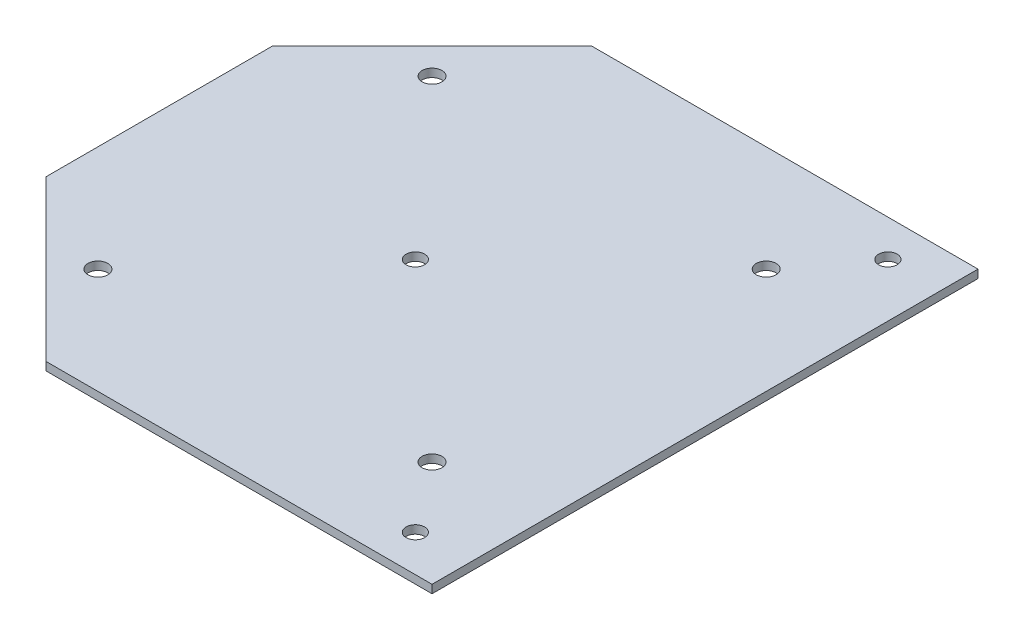
from build123d import *

# Parameters (mm, degrees)
SKETCH1_R           = 3.606945722
SKETCH1_R_2         = 3.375000002
SKETCH1_R_3         = 3.375000001
SKETCH1_R_4         = 3.374999999
BOSS_EXTRUDE1_DEPTH = 3


with BuildPart() as part:
    # Sketch1 → Boss-Extrude1 (new body)
    with BuildSketch(Plane(origin=(0, 0, 0), x_dir=(1, 0, 0), z_dir=(0, 1, 0))):
        Polygon((-41.199524293, 99.465227688), (99.465250609, 99.465227688), (99.465250609, -99.465227688), (-41.199524293, -99.465227688), (-99.465227688, -41.199524293), (-99.465227688, 41.199524293), align=None)
        with Locations((-60.875, 60.875)):
            Circle(SKETCH1_R, mode=Mode.SUBTRACT)
        with Locations((60.875, 60.875)):
            Circle(SKETCH1_R, mode=Mode.SUBTRACT)
        with Locations((60.875, -60.875)):
            Circle(SKETCH1_R, mode=Mode.SUBTRACT)
        with Locations((-60.875, -60.875)):
            Circle(SKETCH1_R, mode=Mode.SUBTRACT)
        with Locations((80.004750061, -86.090249939)):
            Circle(SKETCH1_R_2, mode=Mode.SUBTRACT)
        with Locations((-6.085500548, 6.7e-07)):
            Circle(SKETCH1_R_3, mode=Mode.SUBTRACT)
        with Locations((80.004750061, 86.09025128)):
            Circle(SKETCH1_R_4, mode=Mode.SUBTRACT)
    extrude(amount=BOSS_EXTRUDE1_DEPTH)


solid = part.part
